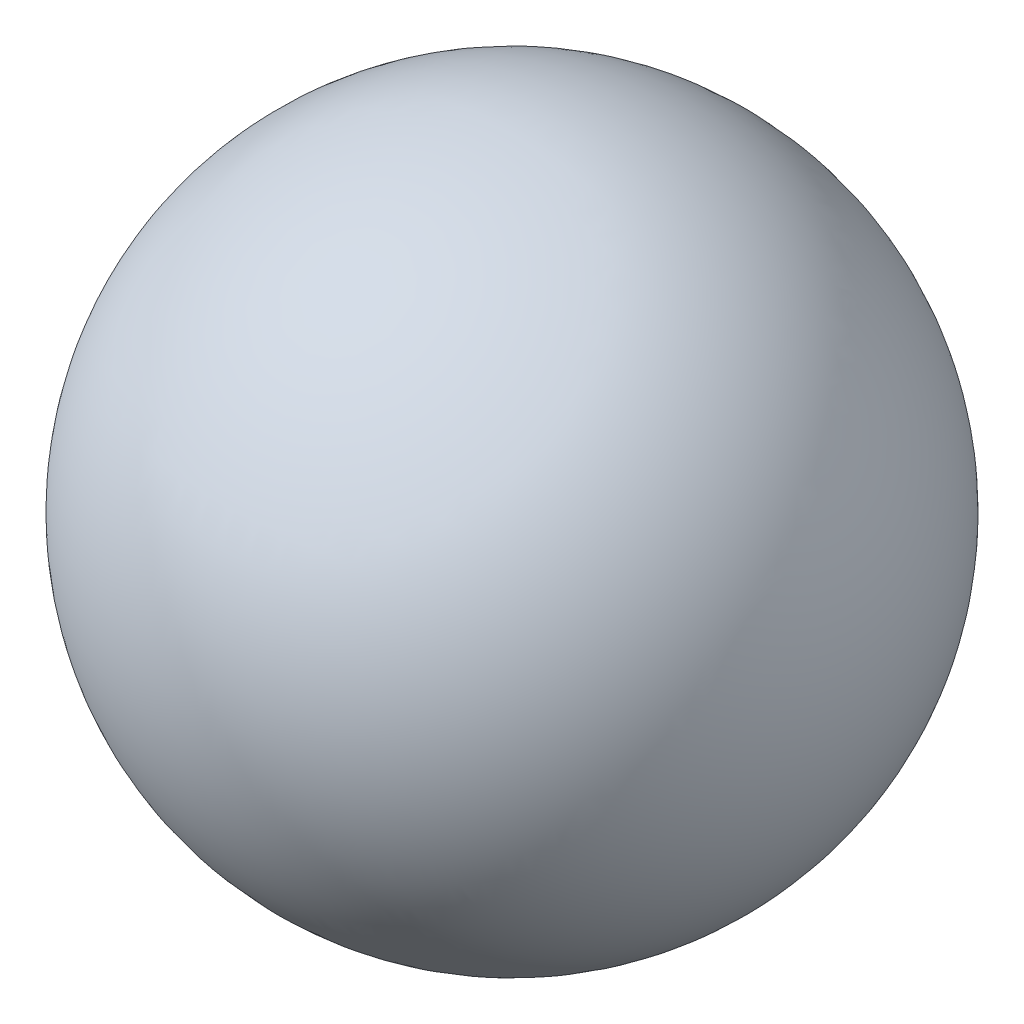
from build123d import *


with BuildPart() as part:
    # Эскиз3 → Revolve 149 (revolve)
    with BuildSketch(Plane.XY):
        with BuildLine():
            Line((-250, 0), (250, 0))
            add(Edge.make_bspline(
                [(250, 0), (250, 250), (0, 250), (-250, 250), (-250, 0)],
                knots=[4.71238898, 4.71238898, 4.71238898, 6.283185307, 6.283185307, 7.853981634, 7.853981634, 7.853981634], degree=2, weights=[1, 0.707106781, 1, 0.707106781, 1]))
        make_face()
    revolve(axis=Axis((-2000, 0, 0), (1, 0, 0)))


solid = part.part
